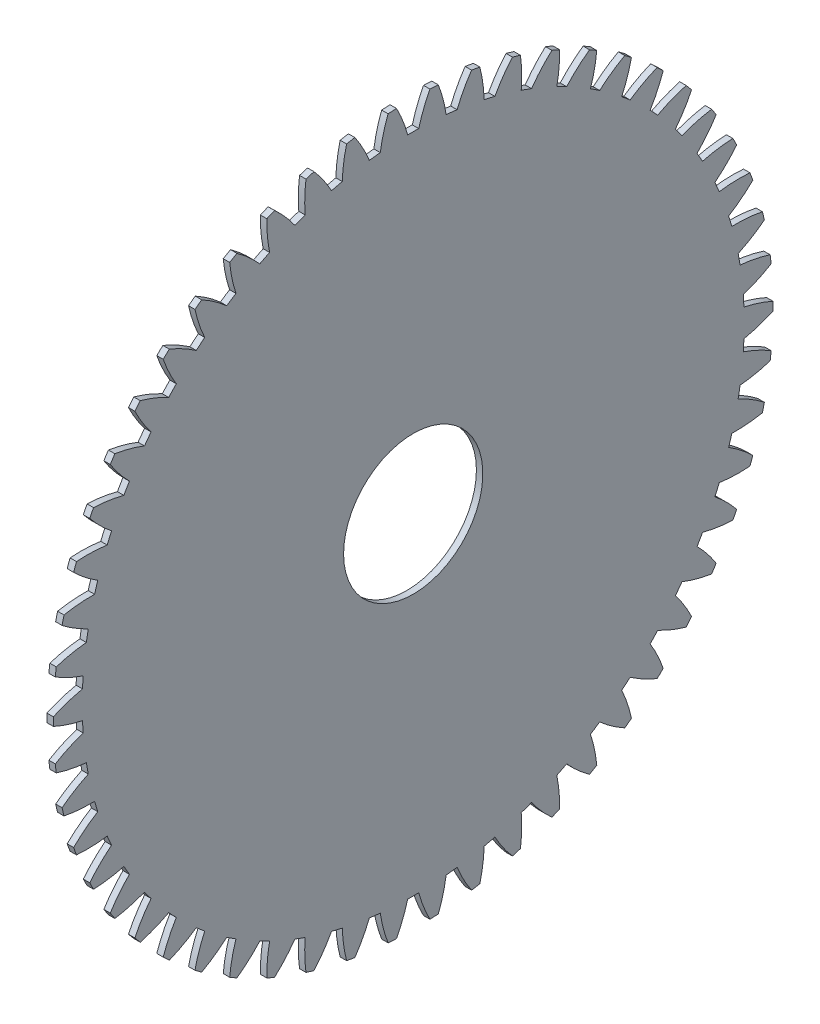
from build123d import *

# Parameters (mm, degrees)
BASPROSKE_W     = 3
BASPROSKE_H     = 168
TOOTHCUT_DEPTH  = 238.606818084
TEETHCUTS_COUNT = 54
TEETHCUTS_ANGLE = 353.333333333
BORSKE_R        = 32.5
BORE_DEPTH      = 50.0000508


with BuildPart() as part:
    # BasProSke → Base-Revolve (revolve)
    with BuildSketch(Plane(origin=(0, 0, 0), x_dir=(1, 0, 0), z_dir=(0, 1, 0)), mode=Mode.PRIVATE) as base_revolve_sk:
        with Locations((1.5, 84)):
            Rectangle(BASPROSKE_W, BASPROSKE_H)
    revolve(base_revolve_sk.sketch.rotate(Axis((-10, 0, 0), (1, 0, 0)), 180), axis=Axis((-10, 0, 0), (1, 0, 0)))

    # TooCutSke → ToothCut (cut, through all)
    with BuildSketch(Plane(origin=(0, 0, 0), x_dir=(0, 0, -1), z_dir=(1, 0, 0))):
        with BuildLine():
            ThreePointArc((2.57234399, 154.477584288), (0, 154.499), (-2.57234399, 154.477584288))
            ThreePointArc((-2.57234399, 154.477584288), (-4.828799492, 161.306320884), (-7.828083298, 167.842950871))
            ThreePointArc((-7.828083298, 167.842950871), (0, 168.0254), (7.828083298, 167.842950871))
            ThreePointArc((7.828083298, 167.842950871), (4.828799492, 161.306320884), (2.57234399, 154.477584288))
        make_face()
    toothcut = extrude(amount=TOOTHCUT_DEPTH, mode=Mode.SUBTRACT)

    # TeethCuts: ToothCut ×54 about axis
    teethcuts_axis = Axis((-10, 0, 0), (1, 0, 0))
    for i in range(1, TEETHCUTS_COUNT):
        add(toothcut.rotate(teethcuts_axis, i * TEETHCUTS_ANGLE / (TEETHCUTS_COUNT - 1)), mode=Mode.SUBTRACT)

    # BorSke → Bore (cut, symmetric)
    with BuildSketch(Plane(origin=(0, 0, 0), x_dir=(0, 0, -1), z_dir=(1, 0, 0))):
        with Locations(Location((0, 0, 0), (0, 0, 180))):
            Circle(BORSKE_R)
    extrude(amount=BORE_DEPTH, both=True, mode=Mode.SUBTRACT)


solid = part.part
